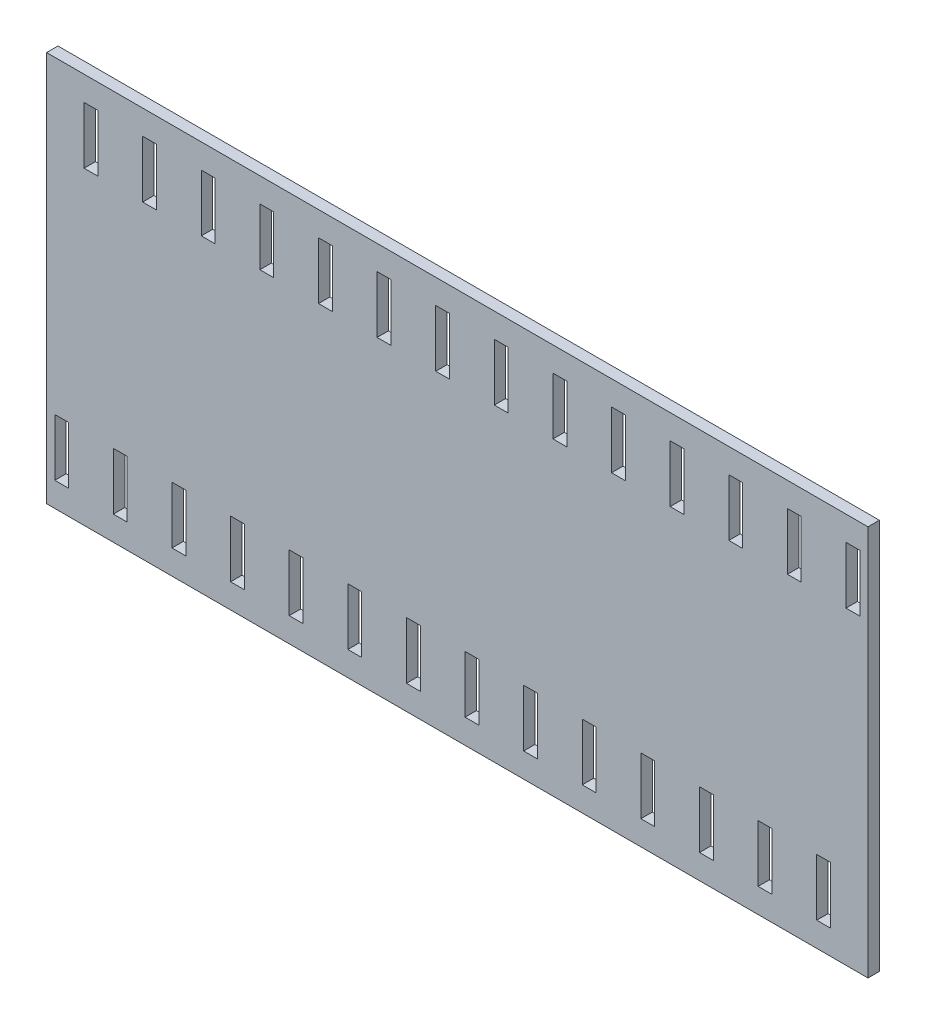
from build123d import *

# Parameters (mm, degrees)
ESQUISSE1_W             = 100.9
ESQUISSE1_H             = 48
BOSS_EXTRU_1_DEPTH      = 1.4
ESQUISSE2_W             = 1.7
ESQUISSE2_H             = 7
ENL_V_MAT_EXTRU_1_DEPTH = 2.4
ESQUISSE3_W             = 0.314102564
ESQUISSE3_H             = 3.5
ENL_V_MAT_EXTRU_2_DEPTH = 0.1


with BuildPart() as part:
    # Esquisse1 → Boss.-Extru.1 (new body)
    with BuildSketch(Plane.XY):
        Rectangle(ESQUISSE1_W, ESQUISSE1_H)
    extrude(amount=BOSS_EXTRU_1_DEPTH)

    # Esquisse2 → Enlèv. mat.-Extru.1 (cut, through all)
    with BuildSketch(Plane(origin=(0, 0, 0), x_dir=(-1, 0, 0), z_dir=(0, 0, -1))):
        with Locations((-48.6, 17.5)):
            Rectangle(ESQUISSE2_W, ESQUISSE2_H)
        with Locations((-41.4, 17.5)):
            Rectangle(ESQUISSE2_W, ESQUISSE2_H)
        with Locations((-34.2, 17.5)):
            Rectangle(ESQUISSE2_W, ESQUISSE2_H)
        with Locations((-27, 17.5)):
            Rectangle(ESQUISSE2_W, ESQUISSE2_H)
        with Locations((-19.8, 17.5)):
            Rectangle(ESQUISSE2_W, ESQUISSE2_H)
        with Locations((-12.6, 17.5)):
            Rectangle(ESQUISSE2_W, ESQUISSE2_H)
        with Locations((-5.4, 17.5)):
            Rectangle(ESQUISSE2_W, ESQUISSE2_H)
        with Locations((1.8, 17.5)):
            Rectangle(ESQUISSE2_W, ESQUISSE2_H)
        with Locations((9, 17.5)):
            Rectangle(ESQUISSE2_W, ESQUISSE2_H)
        with Locations((16.2, 17.5)):
            Rectangle(ESQUISSE2_W, ESQUISSE2_H)
        with Locations((23.4, 17.5)):
            Rectangle(ESQUISSE2_W, ESQUISSE2_H)
        with Locations((30.6, 17.5)):
            Rectangle(ESQUISSE2_W, ESQUISSE2_H)
        with Locations((37.8, 17.5)):
            Rectangle(ESQUISSE2_W, ESQUISSE2_H)
        with Locations((45, 17.5)):
            Rectangle(ESQUISSE2_W, ESQUISSE2_H)
        with Locations((-45, -17.5)):
            Rectangle(ESQUISSE2_W, ESQUISSE2_H)
        with Locations((-37.8, -17.5)):
            Rectangle(ESQUISSE2_W, ESQUISSE2_H)
        with Locations((-30.6, -17.5)):
            Rectangle(ESQUISSE2_W, ESQUISSE2_H)
        with Locations((-23.4, -17.5)):
            Rectangle(ESQUISSE2_W, ESQUISSE2_H)
        with Locations((-16.2, -17.5)):
            Rectangle(ESQUISSE2_W, ESQUISSE2_H)
        with Locations((-9, -17.5)):
            Rectangle(ESQUISSE2_W, ESQUISSE2_H)
        with Locations((-1.8, -17.5)):
            Rectangle(ESQUISSE2_W, ESQUISSE2_H)
        with Locations((5.4, -17.5)):
            Rectangle(ESQUISSE2_W, ESQUISSE2_H)
        with Locations((12.6, -17.5)):
            Rectangle(ESQUISSE2_W, ESQUISSE2_H)
        with Locations((19.8, -17.5)):
            Rectangle(ESQUISSE2_W, ESQUISSE2_H)
        with Locations((27, -17.5)):
            Rectangle(ESQUISSE2_W, ESQUISSE2_H)
        with Locations((34.2, -17.5)):
            Rectangle(ESQUISSE2_W, ESQUISSE2_H)
        with Locations((41.4, -17.5)):
            Rectangle(ESQUISSE2_W, ESQUISSE2_H)
        with Locations((48.6, -17.5)):
            Rectangle(ESQUISSE2_W, ESQUISSE2_H)
    extrude(amount=-ENL_V_MAT_EXTRU_1_DEPTH, mode=Mode.SUBTRACT)

    # Esquisse3 → Enlèv. mat.-Extru.2 (cut)
    with BuildSketch(Plane(origin=(0, 0, 0), x_dir=(-1, 0, 0), z_dir=(0, 0, -1))):
        Polygon((-19.120704868, 1.688016406), (-18.806602304, 1.688016406), (-18.806602304, 0.355183874), (-17.347567849, 1.688016406), (-16.899551022, 1.688016406), (-18.619402784, 0.117503585), (-16.764935637, -1.811983594), (-17.183505349, -1.811983594), (-18.806602304, -0.12298119), (-18.806602304, -1.811983594), (-19.120704868, -1.811983594), align=None)
        with BuildLine():
            Line((-16.248909996, 1.688016406), (-15.548489323, 1.688016406))
            add(Edge.make_bspline(
                [(-15.548489323, 1.688016406), (-15.501748194, 1.68786082), (-15.41200005, 1.687562078), (-15.28342678, 1.685896315), (-15.166599683, 1.681121959), (-15.061579843, 1.677013375), (-14.968369188, 1.669521434), (-14.886681898, 1.662360787), (-14.8168942, 1.652987126), (-14.774648349, 1.644281703), (-14.755520573, 1.640340124)],
                knots=[0, 0, 0, 0, 0.000140226, 0.00026925, 0.000385712, 0.000490995, 0.000584507, 0.000666202, 0.000736998, 0.000795574, 0.000795574, 0.000795574, 0.000795574], degree=3))
            add(Edge.make_bspline(
                [(-14.755520573, 1.640340124), (-14.729913949, 1.634013358), (-14.679246959, 1.621494795), (-14.606296893, 1.595035194), (-14.536782569, 1.564415569), (-14.470992745, 1.528451849), (-14.409256954, 1.486877069), (-14.350938643, 1.440408947), (-14.29577318, 1.389301741), (-14.245991549, 1.3322669), (-14.199052498, 1.27243039), (-14.159463871, 1.207726633), (-14.125337391, 1.140065106), (-14.098166874, 1.068757688), (-14.076288901, 0.994495916), (-14.060862662, 0.916607119), (-14.051611474, 0.835446144), (-14.050669618, 0.780088235), (-14.050192047, 0.75201881)],
                knots=[0, 0, 0, 0, 7.9081e-05, 0.000156475, 0.000232432, 0.000306798, 0.00038108, 0.000455429, 0.000530331, 0.000606314, 0.000682321, 0.000758201, 0.000833453, 0.000909362, 0.000986794, 0.001065445, 0.001147284, 0.001231465, 0.001231465, 0.001231465, 0.001231465], degree=3))
            add(Edge.make_bspline(
                [(-14.050192047, 0.75201881), (-14.051661045, 0.705383705), (-14.054527441, 0.614386537), (-14.081252545, 0.482325656), (-14.125029065, 0.359136341), (-14.185352354, 0.244973703), (-14.262171829, 0.142063058), (-14.35449662, 0.051672603), (-14.462378232, -0.02396731), (-14.562807548, -0.076420115), (-14.651521747, -0.110013023), (-14.72455506, -0.133649382), (-14.804222038, -0.151911347), (-14.889759372, -0.168271479), (-14.981523028, -0.180623174), (-15.079293067, -0.189669768), (-15.183139219, -0.195323817), (-15.254478288, -0.196165822), (-15.291177624, -0.196598979)],
                knots=[0, 0, 0, 0, 0.000139777, 0.000272741, 0.000402249, 0.000530843, 0.000658588, 0.000786009, 0.000916741, 0.001052522, 0.001124656, 0.001201155, 0.001282612, 0.001369656, 0.001462366, 0.001560247, 0.001664165, 0.001774261, 0.001774261, 0.001774261, 0.001774261], degree=3))
            Line((-15.291177624, -0.196598979), (-14.005320252, -1.811983594))
            Line((-14.005320252, -1.811983594), (-14.393741727, -1.811983594))
            Line((-14.393741727, -1.811983594), (-15.679599099, -0.196598979))
            Line((-15.679599099, -0.196598979), (-15.934807432, -0.196598979))
            Line((-15.934807432, -0.196598979), (-15.934807432, -1.811983594))
            Line((-15.934807432, -1.811983594), (-16.248909996, -1.811983594))
            Line((-16.248909996, -1.811983594), (-16.248909996, 1.688016406))
        make_face()
        with BuildLine():
            Line((-15.934807432, 1.329042047), (-15.934807432, 0.16237538))
            Line((-15.934807432, 0.16237538), (-15.293982111, 0.157467528))
            add(Edge.make_bspline(
                [(-15.293982111, 0.157467528), (-15.264062072, 0.157454291), (-15.206068515, 0.157428635), (-15.12216785, 0.161422411), (-15.044047739, 0.165965729), (-14.972006987, 0.172915075), (-14.906013411, 0.181871146), (-14.846099998, 0.193074131), (-14.792168946, 0.206126193), (-14.729270408, 0.226327819), (-14.659033876, 0.258333837), (-14.582702417, 0.304899336), (-14.517700079, 0.363468455), (-14.462782216, 0.430441911), (-14.418652785, 0.50407816), (-14.387540731, 0.583494529), (-14.367798288, 0.666686127), (-14.365469743, 0.723864235), (-14.364294611, 0.752719932)],
                knots=[0, 0, 0, 0, 8.9746e-05, 0.000173954, 0.000251933, 0.000324488, 0.000391021, 0.000451663, 0.000507268, 0.000557378, 0.000649639, 0.000738152, 0.000824558, 0.000910739, 0.000997194, 0.001080909, 0.00116578, 0.001252248, 0.001252248, 0.001252248, 0.001252248], degree=3))
            add(Edge.make_bspline(
                [(-14.364294611, 0.752719932), (-14.365496732, 0.780866505), (-14.367878898, 0.836642744), (-14.387327666, 0.918298654), (-14.420217048, 0.995365604), (-14.464539286, 1.067530089), (-14.518538441, 1.133035825), (-14.581856253, 1.189082978), (-14.652761448, 1.235332443), (-14.719032647, 1.264886823), (-14.778266859, 1.283006677), (-14.829696519, 1.295757841), (-14.887807997, 1.306002309), (-14.952883456, 1.31421037), (-15.024645086, 1.321265315), (-15.103455737, 1.326017093), (-15.188792518, 1.328830957), (-15.247939449, 1.328970046), (-15.278557432, 1.329042047)],
                knots=[0, 0, 0, 0, 8.4371e-05, 0.000167192, 0.000250141, 0.000334794, 0.000420435, 0.000503871, 0.000587493, 0.000673488, 0.0007205, 0.000773215, 0.000832351, 0.0008974, 0.000969955, 0.001048634, 0.001134217, 0.001226067, 0.001226067, 0.001226067, 0.001226067], degree=3))
            Line((-15.278557432, 1.329042047), (-15.934807432, 1.329042047))
        make_face(mode=Mode.SUBTRACT)
        with BuildLine():
            Line((-9.248909996, -1.811983594), (-9.248909996, 1.688016406))
            Line((-9.248909996, 1.688016406), (-8.542179227, 1.688016406))
            add(Edge.make_bspline(
                [(-8.542179227, 1.688016406), (-8.480710239, 1.687573836), (-8.361952473, 1.686718793), (-8.190340026, 1.681297402), (-8.031556263, 1.671706936), (-7.886123404, 1.65773741), (-7.753642192, 1.640584376), (-7.634483584, 1.619083972), (-7.528031441, 1.593695801), (-7.462562001, 1.572050351), (-7.431602304, 1.561814483)],
                knots=[0, 0, 0, 0, 0.000184407, 0.000356273, 0.000515031, 0.000661537, 0.000794508, 0.000915664, 0.001024665, 0.001122454, 0.001122454, 0.001122454, 0.001122454], degree=3))
            add(Edge.make_bspline(
                [(-7.431602304, 1.561814483), (-7.391107564, 1.546383777), (-7.311036372, 1.515872283), (-7.197029249, 1.458315982), (-7.089703887, 1.39310288), (-6.988484742, 1.320147017), (-6.895683915, 1.237382669), (-6.807676019, 1.148325583), (-6.728061295, 1.049737243), (-6.655152999, 0.943662255), (-6.589417339, 0.831350203), (-6.532278181, 0.713015094), (-6.484824188, 0.589257886), (-6.445430961, 0.460422738), (-6.414384504, 0.32622636), (-6.393202572, 0.186512494), (-6.379231582, 0.041833305), (-6.377827531, -0.056341159), (-6.377115124, -0.106154267)],
                knots=[0, 0, 0, 0, 0.000129935, 0.000256923, 0.000382457, 0.000506429, 0.000630624, 0.000755071, 0.000881654, 0.001010204, 0.001140916, 0.00127168, 0.001403968, 0.001538146, 0.001675568, 0.001816774, 0.001961818, 0.002111216, 0.002111216, 0.002111216, 0.002111216], degree=3))
            add(Edge.make_bspline(
                [(-6.377115124, -0.106154267), (-6.377744092, -0.149415506), (-6.378983538, -0.234666295), (-6.390112854, -0.36030719), (-6.406289174, -0.482220762), (-6.431333371, -0.599826462), (-6.461735885, -0.71415468), (-6.500700036, -0.823986924), (-6.545335532, -0.930330733), (-6.597385411, -1.031748209), (-6.654526796, -1.127831581), (-6.715848539, -1.21840711), (-6.781285235, -1.302182331), (-6.851460867, -1.379410943), (-6.925468584, -1.449976522), (-7.003792914, -1.514468537), (-7.086635965, -1.571625092), (-7.173626688, -1.6236922), (-7.267302817, -1.669112556), (-7.369438683, -1.707542566), (-7.480469861, -1.739389181), (-7.600123818, -1.765960077), (-7.728607296, -1.787037379), (-7.866046262, -1.801163772), (-8.012229552, -1.810716704), (-8.112608817, -1.811553098), (-8.164274579, -1.811983594)],
                knots=[0, 0, 0, 0, 0.000129755, 0.000255696, 0.000378151, 0.000498469, 0.000616165, 0.000732801, 0.000847787, 0.000961923, 0.00107447, 0.001182981, 0.001289856, 0.001393094, 0.001495748, 0.001596383, 0.00169713, 0.001797413, 0.001900265, 0.002008995, 0.002124372, 0.002246504, 0.002376522, 0.002514729, 0.002660846, 0.00281582, 0.00281582, 0.00281582, 0.00281582], degree=3))
            Line((-8.164274579, -1.811983594), (-9.248909996, -1.811983594))
        make_face()
        with BuildLine():
            Line((-8.934807432, -1.453009235), (-8.533064643, -1.453009235))
            add(Edge.make_bspline(
                [(-8.533064643, -1.453009235), (-8.475336273, -1.452761139), (-8.364303474, -1.452283959), (-8.204645477, -1.448096755), (-8.05876608, -1.441254818), (-7.926644571, -1.43167974), (-7.808355547, -1.419011125), (-7.703651797, -1.404886222), (-7.612876539, -1.387288771), (-7.557947102, -1.371337812), (-7.532563842, -1.363966767)],
                knots=[0, 0, 0, 0, 0.000173183, 0.000333094, 0.000479096, 0.000611272, 0.000730431, 0.000835931, 0.000928194, 0.001007458, 0.001007458, 0.001007458, 0.001007458], degree=3))
            add(Edge.make_bspline(
                [(-7.532563842, -1.363966767), (-7.50061548, -1.352715209), (-7.437481842, -1.330480836), (-7.346600757, -1.289923175), (-7.261843752, -1.241881105), (-7.181733727, -1.188478831), (-7.107407071, -1.127832829), (-7.037982955, -1.06126184), (-6.973601154, -0.988427065), (-6.914926846, -0.909418903), (-6.862418542, -0.824729108), (-6.816947312, -0.735190274), (-6.777095781, -0.641783464), (-6.745817188, -0.543074305), (-6.721301604, -0.439945247), (-6.703936916, -0.332389033), (-6.693122191, -0.220425752), (-6.691860743, -0.144273627), (-6.691217688, -0.105453145)],
                knots=[0, 0, 0, 0, 0.000101593, 0.000200759, 0.000298073, 0.000393552, 0.000489254, 0.000585454, 0.000681817, 0.000780535, 0.000880346, 0.000980374, 0.001081551, 0.001184655, 0.001290601, 0.001399295, 0.001511268, 0.001627707, 0.001627707, 0.001627707, 0.001627707], degree=3))
            add(Edge.make_bspline(
                [(-6.691217688, -0.105453145), (-6.691730976, -0.064519665), (-6.692739333, 0.015894519), (-6.705413644, 0.133885215), (-6.723935199, 0.247365865), (-6.750718885, 0.35634406), (-6.784849764, 0.461032413), (-6.827444406, 0.560851923), (-6.876111025, 0.656856792), (-6.934014362, 0.746831157), (-6.997429955, 0.831924267), (-7.067807835, 0.909879182), (-7.144029873, 0.980873482), (-7.225264723, 1.046012795), (-7.313801822, 1.102676471), (-7.407555513, 1.153363152), (-7.507901184, 1.196379043), (-7.57771388, 1.219257906), (-7.613192849, 1.230884996)],
                knots=[0, 0, 0, 0, 0.000122746, 0.000241136, 0.000355593, 0.000467485, 0.000577457, 0.000685538, 0.00079278, 0.000899951, 0.001006101, 0.00111085, 0.001214524, 0.001318328, 0.001422759, 0.001529413, 0.00163777, 0.001749741, 0.001749741, 0.001749741, 0.001749741], degree=3))
            add(Edge.make_bspline(
                [(-7.613192849, 1.230884996), (-7.642543995, 1.239001423), (-7.704952585, 1.256259176), (-7.806792049, 1.275084549), (-7.921407199, 1.291689048), (-8.0493069, 1.305747087), (-8.190345359, 1.315834408), (-8.344631047, 1.323405723), (-8.512230651, 1.328512355), (-8.628413185, 1.328861063), (-8.688713682, 1.329042047)],
                knots=[0, 0, 0, 0, 9.1321e-05, 0.000194173, 0.000310382, 0.000438754, 0.000580072, 0.000734511, 0.000902151, 0.001083046, 0.001083046, 0.001083046, 0.001083046], degree=3))
            Line((-8.688713682, 1.329042047), (-8.934807432, 1.329042047))
            Line((-8.934807432, 1.329042047), (-8.934807432, -1.453009235))
        make_face(mode=Mode.SUBTRACT)
        Polygon((-5.659166406, 1.688016406), (-3.684807432, 1.688016406), (-3.684807432, 1.329042047), (-5.345063842, 1.329042047), (-5.345063842, 0.25211897), (-3.684807432, 0.25211897), (-3.684807432, -0.106855389), (-5.345063842, -0.106855389), (-5.345063842, -1.453009235), (-3.684807432, -1.453009235), (-3.684807432, -1.811983594), (-5.659166406, -1.811983594), align=None)
        with BuildLine():
            Line((-3.415576663, -1.136803306), (-3.119703265, -0.959419492))
            add(Edge.make_bspline(
                [(-3.119703265, -0.959419492), (-3.092185028, -1.005483876), (-3.039461147, -1.09374146), (-2.951509788, -1.212999501), (-2.860376877, -1.314361658), (-2.765387543, -1.397238265), (-2.667121595, -1.462487152), (-2.564937542, -1.508689384), (-2.459179731, -1.537505359), (-2.387205909, -1.541005446), (-2.351273778, -1.542752825)],
                knots=[0, 0, 0, 0, 0.000160901, 0.00030828, 0.000443778, 0.00056903, 0.000685513, 0.000796284, 0.00090427, 0.001011928, 0.001011928, 0.001011928, 0.001011928], degree=3))
            add(Edge.make_bspline(
                [(-2.351273778, -1.542752825), (-2.320586917, -1.541898152), (-2.259750144, -1.540203762), (-2.170187901, -1.52392296), (-2.083206099, -1.498910831), (-2.000597461, -1.4630899), (-1.923501847, -1.419751414), (-1.855895152, -1.367405236), (-1.797449038, -1.308799031), (-1.749639924, -1.243416376), (-1.712959889, -1.173099227), (-1.68476782, -1.100923276), (-1.669122747, -1.025754708), (-1.666765993, -0.975144245), (-1.665576663, -0.949603786)],
                knots=[0, 0, 0, 0, 9.1978e-05, 0.000182347, 0.000272202, 0.000362975, 0.000451852, 0.000536835, 0.000618639, 0.000699414, 0.000778765, 0.000855983, 0.0009312, 0.001007828, 0.001007828, 0.001007828, 0.001007828], degree=3))
            add(Edge.make_bspline(
                [(-1.665576663, -0.949603786), (-1.667050973, -0.920462937), (-1.670048032, -0.861223848), (-1.695379512, -0.773824195), (-1.735228758, -0.687331625), (-1.771991402, -0.633830359), (-1.791077464, -0.606054107)],
                knots=[0, 0, 0, 0, 8.7281e-05, 0.000177429, 0.000270909, 0.000371844, 0.000371844, 0.000371844, 0.000371844], degree=3))
            add(Edge.make_bspline(
                [(-1.791077464, -0.606054107), (-1.806748078, -0.586007283), (-1.839646572, -0.543921485), (-1.896204085, -0.481276249), (-1.962570199, -0.41665783), (-2.036473754, -0.347598773), (-2.120606843, -0.277310977), (-2.212334357, -0.202442699), (-2.313998216, -0.125841122), (-2.385297713, -0.074468556), (-2.422087079, -0.047961158)],
                knots=[0, 0, 0, 0, 7.6319e-05, 0.000160223, 0.000252933, 0.000354147, 0.000463581, 0.000581729, 0.000709336, 0.000845369, 0.000845369, 0.000845369, 0.000845369], degree=3))
            add(Edge.make_bspline(
                [(-2.422087079, -0.047961158), (-2.458911075, -0.021732571), (-2.529315752, 0.028414492), (-2.627774334, 0.102838776), (-2.715818797, 0.170882645), (-2.793057814, 0.233186657), (-2.859457411, 0.289759262), (-2.915540822, 0.340057201), (-2.959879379, 0.385440762), (-2.98453496, 0.414882104), (-2.995604707, 0.42810054)],
                knots=[0, 0, 0, 0, 0.000135623, 0.000259301, 0.000370234, 0.000469439, 0.00055697, 0.000631911, 0.000695377, 0.00074709, 0.00074709, 0.00074709, 0.00074709], degree=3))
            add(Edge.make_bspline(
                [(-2.995604707, 0.42810054), (-3.011077253, 0.448701577), (-3.041506089, 0.489216281), (-3.081672095, 0.552541139), (-3.115811258, 0.617364404), (-3.14257359, 0.683860269), (-3.165109809, 0.751095198), (-3.180267739, 0.819946443), (-3.189759136, 0.890105062), (-3.190731123, 0.937318563), (-3.191217688, 0.960953105)],
                knots=[0, 0, 0, 0, 7.727e-05, 0.000151962, 0.000224716, 0.000296717, 0.00036678, 0.0004372, 0.000507902, 0.000578771, 0.000578771, 0.000578771, 0.000578771], degree=3))
            add(Edge.make_bspline(
                [(-3.191217688, 0.960953105), (-3.189912479, 0.997982879), (-3.187329959, 1.071250943), (-3.165489442, 1.178281773), (-3.131016548, 1.280468191), (-3.08272166, 1.376798524), (-3.020464307, 1.464764505), (-2.948418333, 1.545377992), (-2.862606847, 1.613146574), (-2.768454224, 1.672358633), (-2.665397852, 1.718704558), (-2.557406948, 1.753665538), (-2.444309876, 1.773474796), (-2.367706742, 1.776317561), (-2.328837881, 1.777759996)],
                knots=[0, 0, 0, 0, 0.000110999, 0.000219625, 0.000326272, 0.00043382, 0.000541574, 0.000648775, 0.000756959, 0.000868438, 0.000981703, 0.00109501, 0.001208203, 0.0013248, 0.0013248, 0.0013248, 0.0013248], degree=3))
            add(Edge.make_bspline(
                [(-2.328837881, 1.777759996), (-2.28759378, 1.776337444), (-2.205572429, 1.773508443), (-2.084923213, 1.748910912), (-1.968762497, 1.70821024), (-1.875319232, 1.662021582), (-1.80218647, 1.615890166), (-1.746413738, 1.573870342), (-1.689896287, 1.525495233), (-1.632178232, 1.470635987), (-1.574237573, 1.408789236), (-1.51521412, 1.340378547), (-1.454969851, 1.265821991), (-1.416213991, 1.212597491), (-1.396345893, 1.185312079)],
                knots=[0, 0, 0, 0, 0.000123638, 0.000245877, 0.000367608, 0.000492088, 0.000557638, 0.000626769, 0.000701372, 0.00078072, 0.000865532, 0.000955497, 0.001051745, 0.001152989, 0.001152989, 0.001152989, 0.001152989], degree=3))
            Line((-1.396345893, 1.185312079), (-1.68030022, 0.970067688))
            add(Edge.make_bspline(
                [(-1.68030022, 0.970067688), (-1.697446153, 0.992156378), (-1.73046521, 1.034694032), (-1.780594697, 1.094265347), (-1.827843345, 1.148681827), (-1.874393744, 1.195946955), (-1.917787376, 1.238649088), (-1.959904418, 1.275208845), (-2.000138769, 1.30598444), (-2.05085568, 1.338828), (-2.114573398, 1.371384504), (-2.194557935, 1.398933582), (-2.27814421, 1.415488644), (-2.335073841, 1.417677531), (-2.36389397, 1.418785637)],
                knots=[0, 0, 0, 0, 8.3877e-05, 0.000161528, 0.000233552, 0.000299993, 0.000360485, 0.000416152, 0.000467195, 0.000512312, 0.000597287, 0.000681099, 0.000765389, 0.000851809, 0.000851809, 0.000851809, 0.000851809], degree=3))
            add(Edge.make_bspline(
                [(-2.36389397, 1.418785637), (-2.400050493, 1.417573937), (-2.46977494, 1.415237287), (-2.568765176, 1.389717302), (-2.657859101, 1.349535442), (-2.734411666, 1.293220464), (-2.798148643, 1.226499471), (-2.844254102, 1.149720616), (-2.872004267, 1.064938213), (-2.875390546, 1.005796557), (-2.877115124, 0.975676662)],
                knots=[0, 0, 0, 0, 0.000108248, 0.000208746, 0.00030443, 0.000399793, 0.000492054, 0.00057947, 0.000666386, 0.000756591, 0.000756591, 0.000756591, 0.000756591], degree=3))
            add(Edge.make_bspline(
                [(-2.877115124, 0.975676662), (-2.876721998, 0.956925184), (-2.875935101, 0.919391564), (-2.864960304, 0.863940142), (-2.850860975, 0.808628803), (-2.828518343, 0.75370622), (-2.797673039, 0.698211861), (-2.757167863, 0.641190123), (-2.706154551, 0.582138415), (-2.667077539, 0.543731041), (-2.646446054, 0.523453105)],
                knots=[0, 0, 0, 0, 5.616e-05, 0.000112411, 0.000169046, 0.000227244, 0.000289691, 0.000359134, 0.000436702, 0.000523463, 0.000523463, 0.000523463, 0.000523463], degree=3))
            add(Edge.make_bspline(
                [(-2.646446054, 0.523453105), (-2.638784681, 0.516616079), (-2.620583014, 0.50037287), (-2.587307088, 0.47378059), (-2.54336429, 0.440977818), (-2.489902089, 0.400390501), (-2.425934727, 0.353309039), (-2.351455171, 0.300335427), (-2.267293638, 0.239749968), (-2.207571722, 0.197392427), (-2.175993329, 0.174995573)],
                knots=[0, 0, 0, 0, 3.0802e-05, 7.3177e-05, 0.000127725, 0.000195314, 0.000274544, 0.000365991, 0.000469501, 0.000585644, 0.000585644, 0.000585644, 0.000585644], degree=3))
            add(Edge.make_bspline(
                [(-2.175993329, 0.174995573), (-2.138007416, 0.147354213), (-2.06445296, 0.093830551), (-1.95979538, 0.013414871), (-1.864901572, -0.065232897), (-1.779438368, -0.141610504), (-1.70256146, -0.215138597), (-1.635123739, -0.286701778), (-1.576438059, -0.35578735), (-1.51325884, -0.444359926), (-1.448701021, -0.55314101), (-1.393259513, -0.686419249), (-1.358301166, -0.820215569), (-1.35372965, -0.910142406), (-1.351474099, -0.954511639)],
                knots=[0, 0, 0, 0, 0.000140932, 0.000272896, 0.000395881, 0.000510584, 0.000616697, 0.000714904, 0.000805482, 0.000888372, 0.001041088, 0.001183793, 0.001320341, 0.001453327, 0.001453327, 0.001453327, 0.001453327], degree=3))
            add(Edge.make_bspline(
                [(-1.351474099, -0.954511639), (-1.352131237, -0.985890004), (-1.353432752, -1.048037388), (-1.368393665, -1.139292465), (-1.390313331, -1.227923334), (-1.423350565, -1.312834447), (-1.463673723, -1.395579209), (-1.514839971, -1.47398711), (-1.574147655, -1.549793508), (-1.64218142, -1.620977), (-1.716627323, -1.686323196), (-1.795311017, -1.744452257), (-1.87836129, -1.792920581), (-1.965327607, -1.832471423), (-2.056229944, -1.86340494), (-2.151037728, -1.885817809), (-2.249907239, -1.89957352), (-2.31710772, -1.901001282), (-2.351273778, -1.901727184)],
                knots=[0, 0, 0, 0, 9.4044e-05, 0.000186263, 0.000276729, 0.000367488, 0.000459046, 0.000552398, 0.000647774, 0.000747454, 0.000847311, 0.000944634, 0.001040472, 0.001135227, 0.001230788, 0.001328063, 0.00142712, 0.00152957, 0.00152957, 0.00152957, 0.00152957], degree=3))
            add(Edge.make_bspline(
                [(-2.351273778, -1.901727184), (-2.377709121, -1.901216002), (-2.430246881, -1.900200077), (-2.507956363, -1.891218796), (-2.584095952, -1.878511693), (-2.657710234, -1.858337623), (-2.729747646, -1.833860646), (-2.79989488, -1.803722313), (-2.868185934, -1.767605112), (-2.935003517, -1.726310087), (-3.000177692, -1.678252343), (-3.06309716, -1.622278846), (-3.125826345, -1.559933341), (-3.186513741, -1.489522778), (-3.246386886, -1.412184695), (-3.304265295, -1.327195512), (-3.361347013, -1.235018158), (-3.397162481, -1.170153072), (-3.415576663, -1.136803306)],
                knots=[0, 0, 0, 0, 7.9276e-05, 0.000157554, 0.000234438, 0.000310629, 0.000386236, 0.000462555, 0.000539392, 0.000617798, 0.000698008, 0.000781971, 0.000870217, 0.00096315, 0.001060616, 0.001163492, 0.001271478, 0.00138575, 0.00138575, 0.00138575, 0.00138575], degree=3))
        make_face()
        with BuildLine():
            add(Edge.make_bspline(
                [(1.004295132, 1.777759996), (1.069103238, 1.776118516), (1.196391705, 1.772894515), (1.383466603, 1.748215412), (1.562061698, 1.705520022), (1.733631837, 1.648657039), (1.896124813, 1.572802654), (2.050763706, 1.481117506), (2.19718058, 1.372641047), (2.333401961, 1.24821182), (2.458058912, 1.112828366), (2.567884798, 0.968350456), (2.659927092, 0.815651654), (2.735512879, 0.655190823), (2.794811488, 0.487330855), (2.835730532, 0.311176852), (2.861868682, 0.127870162), (2.86492446, 0.002843298), (2.866474619, -0.060581351)],
                knots=[0, 0, 0, 0, 0.000194393, 0.000381804, 0.00056479, 0.000744601, 0.000923091, 0.001101652, 0.001283106, 0.001468738, 0.001654324, 0.001834514, 0.002012231, 0.002188181, 0.002365797, 0.002545211, 0.002729936, 0.002920126, 0.002920126, 0.002920126, 0.002920126], degree=3))
            add(Edge.make_bspline(
                [(2.866474619, -0.060581351), (2.864924687, -0.123538797), (2.86186959, -0.247635217), (2.835700813, -0.429778661), (2.794659813, -0.604869358), (2.736063547, -0.772615011), (2.660838068, -0.933192575), (2.568182897, -1.086179528), (2.459041686, -1.231626027), (2.334834835, -1.367938692), (2.199433793, -1.492936163), (2.054203526, -1.601855038), (1.902410207, -1.695579163), (1.742100498, -1.770362837), (1.575400462, -1.830134757), (1.400818138, -1.870887387), (1.219171584, -1.897174431), (1.095300581, -1.900192947), (1.032340004, -1.901727184)],
                knots=[0, 0, 0, 0, 0.000188789, 0.000372126, 0.000550857, 0.00072758, 0.000904164, 0.001081881, 0.001263191, 0.001448823, 0.00163441, 0.001815159, 0.001992641, 0.002168591, 0.002344885, 0.002522934, 0.002705576, 0.002894365, 0.002894365, 0.002894365, 0.002894365], degree=3))
            add(Edge.make_bspline(
                [(1.032340004, -1.901727184), (0.968915685, -1.900177797), (0.843889469, -1.897123543), (0.660352434, -1.870942138), (0.48407469, -1.830000834), (0.315560339, -1.771491398), (0.154715409, -1.695874168), (0.001225326, -1.603669788), (-0.144293821, -1.494262647), (-0.280635567, -1.370096073), (-0.405384766, -1.234924521), (-0.514144141, -1.090090266), (-0.606369255, -0.938434809), (-0.681732587, -0.779537285), (-0.741397046, -0.614165842), (-0.782101865, -0.441217365), (-0.808437817, -0.261677859), (-0.811472663, -0.139434961), (-0.81301256, -0.077408274)],
                knots=[0, 0, 0, 0, 0.00019019, 0.000374915, 0.000555011, 0.000732396, 0.00090898, 0.001087298, 0.001268608, 0.00145424, 0.001639827, 0.001819595, 0.001996712, 0.002171394, 0.002346367, 0.002523053, 0.002703612, 0.002889599, 0.002889599, 0.002889599, 0.002889599], degree=3))
            add(Edge.make_bspline(
                [(-0.81301256, -0.077408274), (-0.812477925, -0.035775604), (-0.811415398, 0.046964519), (-0.798623706, 0.169831119), (-0.780062005, 0.290721777), (-0.753460092, 0.409292725), (-0.718668425, 0.52525371), (-0.677616398, 0.639404472), (-0.627476552, 0.750588196), (-0.570795904, 0.859331588), (-0.507534096, 0.963939494), (-0.437658347, 1.062819077), (-0.363622978, 1.156800074), (-0.282459585, 1.243447078), (-0.196843139, 1.325280734), (-0.105384761, 1.401043451), (-0.008642517, 1.471418402), (0.093799863, 1.534838743), (0.199418138, 1.592197878), (0.308294915, 1.641419729), (0.418951487, 1.68366579), (0.531906135, 1.717906615), (0.646858907, 1.744938651), (0.764060692, 1.763346005), (0.883418118, 1.776170323), (0.963829437, 1.777227825), (1.004295132, 1.777759996)],
                knots=[0, 0, 0, 0, 0.000124849, 0.000248123, 0.000370193, 0.00049164, 0.000612319, 0.000733199, 0.000855287, 0.000977905, 0.001100913, 0.001221706, 0.001340948, 0.001459521, 0.001577551, 0.001696047, 0.001815534, 0.001936153, 0.002057243, 0.002175846, 0.002294342, 0.002412335, 0.002529682, 0.00264829, 0.002768075, 0.00288942, 0.00288942, 0.00288942, 0.00288942], degree=3))
        make_face()
        with BuildLine():
            add(Edge.make_bspline(
                [(1.019719812, 1.418785637), (0.986505178, 1.418380746), (0.920393445, 1.417574837), (0.822108909, 1.406959121), (0.725116975, 1.391829232), (0.629397613, 1.370247711), (0.535351324, 1.340843659), (0.442101482, 1.30700275), (0.350498429, 1.26578166), (0.260844571, 1.219208955), (0.173929496, 1.167660035), (0.091916794, 1.110688268), (0.01459415, 1.049629713), (-0.057849116, 0.984341876), (-0.125200289, 0.914492274), (-0.18878499, 0.841139838), (-0.246054572, 0.762187947), (-0.298540149, 0.67977754), (-0.345507989, 0.594015959), (-0.387273344, 0.505806097), (-0.421437352, 0.41442841), (-0.449299729, 0.320874252), (-0.47239954, 0.225291793), (-0.487033464, 0.126955944), (-0.497765823, 0.026360832), (-0.498525669, -0.041621022), (-0.498909996, -0.07600603)],
                knots=[0, 0, 0, 0, 9.9599e-05, 0.000198245, 0.000296222, 0.00039402, 0.00049227, 0.000591646, 0.000691452, 0.000793368, 0.000894612, 0.000994383, 0.001092713, 0.00119001, 0.001286696, 0.001383657, 0.001480979, 0.001579008, 0.001676595, 0.001774142, 0.001871547, 0.001968922, 0.002066879, 0.00216624, 0.00226698, 0.002370083, 0.002370083, 0.002370083, 0.002370083], degree=3))
            add(Edge.make_bspline(
                [(-0.498909996, -0.07600603), (-0.497635134, -0.126568251), (-0.495127086, -0.226039781), (-0.473169516, -0.371807925), (-0.439347542, -0.511896211), (-0.389490175, -0.645538121), (-0.32713956, -0.773882403), (-0.25011267, -0.895790508), (-0.158853585, -1.011295382), (-0.055190058, -1.119590651), (0.058132649, -1.218436456), (0.178465379, -1.305199864), (0.304518986, -1.378610114), (0.436622189, -1.438415187), (0.574069728, -1.485804924), (0.717747279, -1.518283555), (0.866697738, -1.539659011), (0.968228394, -1.541711767), (1.019719812, -1.542752825)],
                knots=[0, 0, 0, 0, 0.000151605, 0.000298253, 0.000441263, 0.000583229, 0.000725274, 0.000868635, 0.001014928, 0.001166177, 0.001317744, 0.00146543, 0.001610576, 0.001754594, 0.001899821, 0.002045914, 0.002195936, 0.002350312, 0.002350312, 0.002350312, 0.002350312], degree=3))
            add(Edge.make_bspline(
                [(1.019719812, -1.542752825), (1.054329313, -1.542277321), (1.12297035, -1.541334253), (1.225065872, -1.531835576), (1.325322084, -1.516603706), (1.423598364, -1.494673051), (1.519783175, -1.467225844), (1.614277978, -1.434618116), (1.706076269, -1.393936913), (1.796336106, -1.348988961), (1.882732348, -1.297748804), (1.96520788, -1.242710654), (2.04168386, -1.181742033), (2.114072932, -1.117424221), (2.181700621, -1.048460373), (2.244109605, -0.974940151), (2.301089737, -0.896399494), (2.353555384, -0.814114088), (2.400358646, -0.728117835), (2.441137745, -0.639588157), (2.475733861, -0.548743048), (2.503662366, -0.455451476), (2.525547828, -0.359890628), (2.540627748, -0.261932549), (2.551176186, -0.161773207), (2.551971263, -0.094029351), (2.552372055, -0.059880229)],
                knots=[0, 0, 0, 0, 0.000103804, 0.000205874, 0.000307314, 0.000407849, 0.000507719, 0.000607281, 0.000707445, 0.000808723, 0.000909609, 0.001008589, 0.001105934, 0.001202762, 0.001298946, 0.001395452, 0.001491794, 0.001589823, 0.001688026, 0.001785277, 0.001882027, 0.001979402, 0.0020772, 0.002175869, 0.002276609, 0.002379011, 0.002379011, 0.002379011, 0.002379011], degree=3))
            add(Edge.make_bspline(
                [(2.552372055, -0.059880229), (2.551970942, -0.025964724), (2.551175261, 0.041312926), (2.540632786, 0.140773744), (2.525531896, 0.238026956), (2.503769188, 0.332690759), (2.475719034, 0.424789284), (2.441131704, 0.514236031), (2.400346404, 0.601364226), (2.35353818, 0.685958523), (2.300922356, 0.767133261), (2.243428113, 0.844735674), (2.180062765, 0.917308415), (2.11263674, 0.986643109), (2.039465855, 1.051260999), (1.960881561, 1.11118352), (1.877837883, 1.167856794), (1.789910647, 1.218982356), (1.699166694, 1.266196588), (1.606052736, 1.306647592), (1.511623636, 1.341019711), (1.416119524, 1.370336676), (1.318736545, 1.391744706), (1.220132717, 1.406972756), (1.120444458, 1.417571142), (1.053401238, 1.41837952), (1.019719812, 1.418785637)],
                knots=[0, 0, 0, 0, 0.000101701, 0.000201743, 0.00029972, 0.000396835, 0.000492868, 0.000588308, 0.000684288, 0.000781261, 0.000878109, 0.000974304, 0.001070733, 0.001166917, 0.001264269, 0.001363274, 0.001463228, 0.001565678, 0.001668217, 0.001769947, 0.001869982, 0.001969573, 0.002069423, 0.002168785, 0.002268827, 0.002369827, 0.002369827, 0.002369827, 0.002369827], degree=3))
        make_face(mode=Mode.SUBTRACT)
        Polygon((3.584423337, 1.688016406), (3.898525901, 1.688016406), (3.898525901, -1.453009235), (5.244679748, -1.453009235), (5.244679748, -1.811983594), (3.584423337, -1.811983594), align=None)
        Polygon((5.558782312, 1.688016406), (5.895320773, 1.688016406), (7.06198744, -1.070196735), (8.228654107, 1.688016406), (8.565192568, 1.688016406), (7.084423337, -1.811983594), (7.039551543, -1.811983594), align=None)
        Polygon((10.629295132, 1.688016406), (12.244679748, -1.811983594), (11.903233434, -1.811983594), (11.385805549, -0.690188722), (9.799166927, -0.690188722), (9.267015485, -1.811983594), (8.924166927, -1.811983594), (10.584423337, 1.688016406), align=None)
        Polygon((10.603353626, 1.005824899), (9.969539523, -0.331214363), (11.220340805, -0.331214363), align=None, mode=Mode.SUBTRACT)
        Polygon((12.469038722, 1.329042047), (12.469038722, 1.688016406), (14.308782312, 1.688016406), (14.308782312, 1.329042047), (13.545961799, 1.329042047), (13.545961799, -1.811983594), (13.231859235, -1.811983594), (13.231859235, 1.329042047), align=None)
        with Locations((15.004295132, -0.061983594)):
            Rectangle(ESQUISSE3_W, ESQUISSE3_H)
        with BuildLine():
            add(Edge.make_bspline(
                [(17.696602825, 1.777759996), (17.76141093, 1.776118516), (17.888699397, 1.772894515), (18.075774295, 1.748215412), (18.25436939, 1.705520022), (18.425939529, 1.648657039), (18.588432506, 1.572802654), (18.743071398, 1.481117506), (18.889488272, 1.372641047), (19.025709654, 1.24821182), (19.150366604, 1.112828366), (19.26019249, 0.968350456), (19.352234784, 0.815651654), (19.427820571, 0.655190823), (19.487119181, 0.487330855), (19.528038224, 0.311176852), (19.554176375, 0.127870162), (19.557232152, 0.002843298), (19.558782312, -0.060581351)],
                knots=[0, 0, 0, 0, 0.000194393, 0.000381804, 0.00056479, 0.000744601, 0.000923091, 0.001101652, 0.001283106, 0.001468738, 0.001654324, 0.001834514, 0.002012231, 0.002188181, 0.002365797, 0.002545211, 0.002729936, 0.002920126, 0.002920126, 0.002920126, 0.002920126], degree=3))
            add(Edge.make_bspline(
                [(19.558782312, -0.060581351), (19.557232379, -0.123538797), (19.554177283, -0.247635217), (19.528008505, -0.429778661), (19.486967505, -0.604869358), (19.428371239, -0.772615011), (19.35314576, -0.933192575), (19.260490589, -1.086179528), (19.151349379, -1.231626027), (19.027142528, -1.367938692), (18.891741486, -1.492936163), (18.746511219, -1.601855038), (18.594717899, -1.695579163), (18.434408191, -1.770362837), (18.267708154, -1.830134757), (18.093125831, -1.870887387), (17.911479277, -1.897174431), (17.787608273, -1.900192947), (17.724647696, -1.901727184)],
                knots=[0, 0, 0, 0, 0.000188789, 0.000372126, 0.000550857, 0.00072758, 0.000904164, 0.001081881, 0.001263191, 0.001448823, 0.00163441, 0.001815159, 0.001992641, 0.002168591, 0.002344885, 0.002522934, 0.002705576, 0.002894365, 0.002894365, 0.002894365, 0.002894365], degree=3))
            add(Edge.make_bspline(
                [(17.724647696, -1.901727184), (17.661223377, -1.900177797), (17.536197161, -1.897123543), (17.352660126, -1.870942138), (17.176382382, -1.830000834), (17.007868031, -1.771491398), (16.847023101, -1.695874168), (16.693533019, -1.603669788), (16.548013871, -1.494262647), (16.411672125, -1.370096073), (16.286922927, -1.234924521), (16.178163551, -1.090090266), (16.085938438, -0.938434809), (16.010575105, -0.779537285), (15.950910646, -0.614165842), (15.910205828, -0.441217365), (15.883869876, -0.261677859), (15.880835029, -0.139434961), (15.879295132, -0.077408274)],
                knots=[0, 0, 0, 0, 0.00019019, 0.000374915, 0.000555011, 0.000732396, 0.00090898, 0.001087298, 0.001268608, 0.00145424, 0.001639827, 0.001819595, 0.001996712, 0.002171394, 0.002346367, 0.002523053, 0.002703612, 0.002889599, 0.002889599, 0.002889599, 0.002889599], degree=3))
            add(Edge.make_bspline(
                [(15.879295132, -0.077408274), (15.879829768, -0.035775604), (15.880892294, 0.046964519), (15.893683987, 0.169831119), (15.912245688, 0.290721777), (15.9388476, 0.409292725), (15.973639267, 0.52525371), (16.014691295, 0.639404472), (16.06483114, 0.750588196), (16.121511788, 0.859331588), (16.184773596, 0.963939494), (16.254649346, 1.062819077), (16.328684714, 1.156800074), (16.409848108, 1.243447078), (16.495464553, 1.325280734), (16.586922931, 1.401043451), (16.683665175, 1.471418402), (16.786107555, 1.534838743), (16.89172583, 1.592197878), (17.000602608, 1.641419729), (17.111259179, 1.68366579), (17.224213827, 1.717906615), (17.339166599, 1.744938651), (17.456368384, 1.763346005), (17.57572581, 1.776170323), (17.656137129, 1.777227825), (17.696602825, 1.777759996)],
                knots=[0, 0, 0, 0, 0.000124849, 0.000248123, 0.000370193, 0.00049164, 0.000612319, 0.000733199, 0.000855287, 0.000977905, 0.001100913, 0.001221706, 0.001340948, 0.001459521, 0.001577551, 0.001696047, 0.001815534, 0.001936153, 0.002057243, 0.002175846, 0.002294342, 0.002412335, 0.002529682, 0.00264829, 0.002768075, 0.00288942, 0.00288942, 0.00288942, 0.00288942], degree=3))
        make_face()
        with BuildLine():
            add(Edge.make_bspline(
                [(17.712027504, 1.418785637), (17.678812871, 1.418380746), (17.612701138, 1.417574837), (17.514416601, 1.406959121), (17.417424667, 1.391829232), (17.321705305, 1.370247711), (17.227659016, 1.340843659), (17.134409175, 1.30700275), (17.042806121, 1.26578166), (16.953152263, 1.219208955), (16.866237188, 1.167660035), (16.784224486, 1.110688268), (16.706901842, 1.049629713), (16.634458576, 0.984341876), (16.567107404, 0.914492274), (16.503522702, 0.841139838), (16.446253121, 0.762187947), (16.393767544, 0.67977754), (16.346799703, 0.594015959), (16.305034349, 0.505806097), (16.27087034, 0.41442841), (16.243007964, 0.320874252), (16.219908153, 0.225291793), (16.205274229, 0.126955944), (16.194541869, 0.026360832), (16.193782024, -0.041621022), (16.193397696, -0.07600603)],
                knots=[0, 0, 0, 0, 9.9599e-05, 0.000198245, 0.000296222, 0.00039402, 0.00049227, 0.000591646, 0.000691452, 0.000793368, 0.000894612, 0.000994383, 0.001092713, 0.00119001, 0.001286696, 0.001383657, 0.001480979, 0.001579008, 0.001676595, 0.001774142, 0.001871547, 0.001968922, 0.002066879, 0.00216624, 0.00226698, 0.002370083, 0.002370083, 0.002370083, 0.002370083], degree=3))
            add(Edge.make_bspline(
                [(16.193397696, -0.07600603), (16.194672558, -0.126568251), (16.197180606, -0.226039781), (16.219138176, -0.371807925), (16.252960151, -0.511896211), (16.302817517, -0.645538121), (16.365168132, -0.773882403), (16.442195022, -0.895790508), (16.533454108, -1.011295382), (16.637117634, -1.119590651), (16.750440341, -1.218436456), (16.870773071, -1.305199864), (16.996826678, -1.378610114), (17.128929881, -1.438415187), (17.26637742, -1.485804924), (17.410054971, -1.518283555), (17.559005431, -1.539659011), (17.660536086, -1.541711767), (17.712027504, -1.542752825)],
                knots=[0, 0, 0, 0, 0.000151605, 0.000298253, 0.000441263, 0.000583229, 0.000725274, 0.000868635, 0.001014928, 0.001166177, 0.001317744, 0.00146543, 0.001610576, 0.001754594, 0.001899821, 0.002045914, 0.002195936, 0.002350312, 0.002350312, 0.002350312, 0.002350312], degree=3))
            add(Edge.make_bspline(
                [(17.712027504, -1.542752825), (17.746637006, -1.542277321), (17.815278042, -1.541334253), (17.917373564, -1.531835576), (18.017629776, -1.516603706), (18.115906056, -1.494673051), (18.212090867, -1.467225844), (18.306585671, -1.434618116), (18.398383961, -1.393936913), (18.488643799, -1.348988961), (18.57504004, -1.297748804), (18.657515573, -1.242710654), (18.733991552, -1.181742033), (18.806380624, -1.117424221), (18.874008313, -1.048460373), (18.936417297, -0.974940151), (18.993397429, -0.896399494), (19.045863076, -0.814114088), (19.092666339, -0.728117835), (19.133445438, -0.639588157), (19.168041553, -0.548743048), (19.195970058, -0.455451476), (19.21785552, -0.359890628), (19.23293544, -0.261932549), (19.243483879, -0.161773207), (19.244278956, -0.094029351), (19.244679748, -0.059880229)],
                knots=[0, 0, 0, 0, 0.000103804, 0.000205874, 0.000307314, 0.000407849, 0.000507719, 0.000607281, 0.000707445, 0.000808723, 0.000909609, 0.001008589, 0.001105934, 0.001202762, 0.001298946, 0.001395452, 0.001491794, 0.001589823, 0.001688026, 0.001785277, 0.001882027, 0.001979402, 0.0020772, 0.002175869, 0.002276609, 0.002379011, 0.002379011, 0.002379011, 0.002379011], degree=3))
            add(Edge.make_bspline(
                [(19.244679748, -0.059880229), (19.244278635, -0.025964724), (19.243482953, 0.041312926), (19.232940479, 0.140773744), (19.217839588, 0.238026956), (19.19607688, 0.332690759), (19.168026726, 0.424789284), (19.133439396, 0.514236031), (19.092654097, 0.601364226), (19.045845872, 0.685958523), (18.993230049, 0.767133261), (18.935735805, 0.844735674), (18.872370457, 0.917308415), (18.804944432, 0.986643109), (18.731773547, 1.051260999), (18.653189253, 1.11118352), (18.570145575, 1.167856794), (18.48221834, 1.218982356), (18.391474386, 1.266196588), (18.298360428, 1.306647592), (18.203931328, 1.341019711), (18.108427216, 1.370336676), (18.011044238, 1.391744706), (17.912440409, 1.406972756), (17.81275215, 1.417571142), (17.745708931, 1.41837952), (17.712027504, 1.418785637)],
                knots=[0, 0, 0, 0, 0.000101701, 0.000201743, 0.00029972, 0.000396835, 0.000492868, 0.000588308, 0.000684288, 0.000781261, 0.000878109, 0.000974304, 0.001070733, 0.001166917, 0.001264269, 0.001363274, 0.001463228, 0.001565678, 0.001668217, 0.001769947, 0.001869982, 0.001969573, 0.002069423, 0.002168785, 0.002268827, 0.002369827, 0.002369827, 0.002369827, 0.002369827], degree=3))
        make_face(mode=Mode.SUBTRACT)
        Polygon((20.27673103, -1.811983594), (20.27673103, 1.688016406), (20.342636478, 1.688016406), (22.654936158, -1.066691126), (22.654936158, 1.688016406), (22.969038722, 1.688016406), (22.969038722, -1.811983594), (22.897524299, -1.811983594), (20.590833594, 0.936413842), (20.590833594, -1.811983594), align=None)
    extrude(amount=-ENL_V_MAT_EXTRU_2_DEPTH, mode=Mode.SUBTRACT)


solid = part.part
